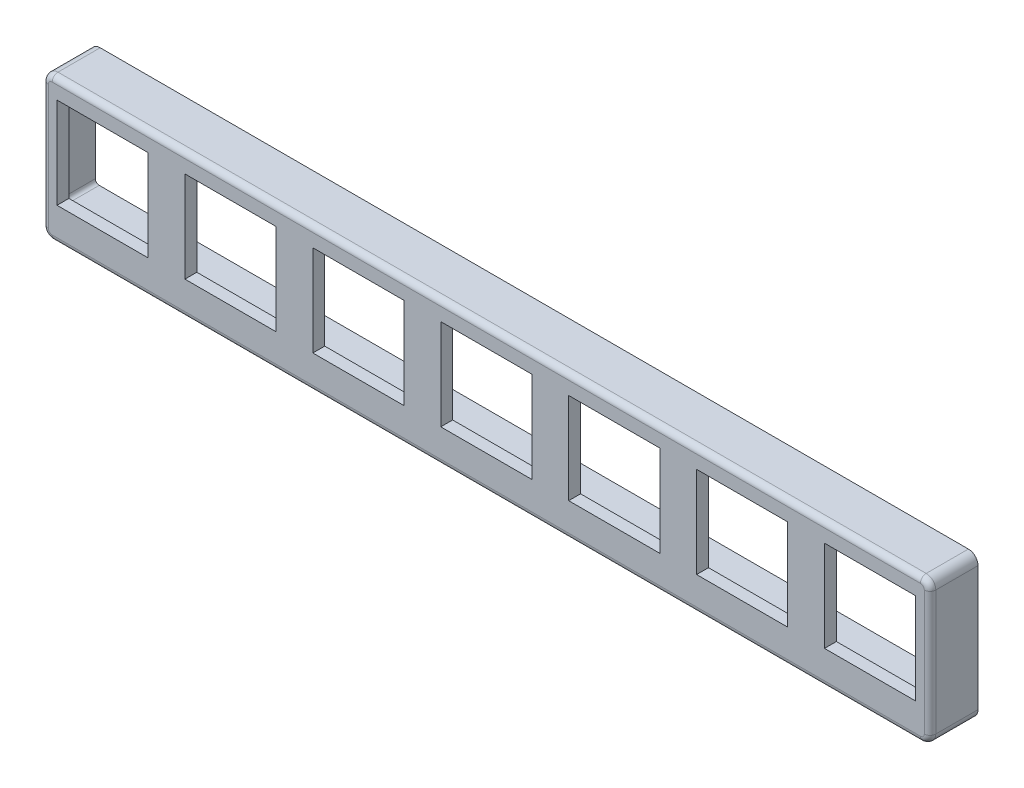
from build123d import *

# Parameters (mm, degrees)
SKETCH1_W             = 117.475
SKETCH1_H             = 19.05
BOSS_EXTRUDE1_DEPTH   = 9.525
BOSS_EXTRUDE2_DEPTH   = 3.175
F_6_CLEARANCE_HOLE1_D = 4.3053
SKETCH5_W             = 12.065
SKETCH5_H             = 12.065
CUT_EXTRUDE1_DEPTH    = 10.525
SKETCH7_W             = 116.205
SKETCH7_H             = 14.605
CUT_EXTRUDE2_DEPTH    = 7.9502
SKETCH8_W             = 117.475
SKETCH8_H             = 28.575
CUT_EXTRUDE3_DEPTH    = 3.175
FILLET2_R             = 1.27
FILLET3_R             = 0.762
FILLET4_R             = 0.508


with BuildPart() as part:
    # Sketch1 → Boss-Extrude1 (new body)
    with BuildSketch(Plane.XY):
        with Locations((0, -57.6104797)):
            Rectangle(SKETCH1_W, SKETCH1_H)
    extrude(amount=BOSS_EXTRUDE1_DEPTH)

    # Sketch2 → Boss-Extrude2 (add)
    with BuildSketch(Plane.XY):
        with BuildLine():
            Line((35.56, -48.0854797), (58.7375, -48.0854797))
            Line((58.7375, -48.0854797), (44.939976119, -39.26086832))
            ThreePointArc((44.939976119, -39.26086832), (40.410479427, -39.106525106), (38.1, -43.0054797))
            Line((38.1, -43.0054797), (38.1, -45.5454797))
            ThreePointArc((38.1, -45.5454797), (37.356051224, -47.341530924), (35.56, -48.0854797))
        make_face()
        with BuildLine():
            Line((-38.1, -45.5454797), (-38.1, -43.0054797))
            ThreePointArc((-38.1, -43.0054797), (-40.410479427, -39.106525106), (-44.939976119, -39.26086832))
            Line((-44.939976119, -39.26086832), (-58.7375, -48.0854797))
            Line((-58.7375, -48.0854797), (-35.56, -48.0854797))
            ThreePointArc((-35.56, -48.0854797), (-37.356051224, -47.341530924), (-38.1, -45.5454797))
        make_face()
    extrude(amount=BOSS_EXTRUDE2_DEPTH)

    # #6 Clearance Hole1 (through all)
    with Locations(Plane.XY.offset(3.175)):
        with Locations((42.545, -43.0054797), (-42.545, -43.0054797)):
            Hole(F_6_CLEARANCE_HOLE1_D / 2)

    # Sketch5 → Cut-Extrude1 (cut, through all)
    with BuildSketch(Plane.XY.offset(9.525)):
        with Locations((50.8, -56.6198797)):
            Rectangle(SKETCH5_W, SKETCH5_H)
        with Locations((33.866666667, -56.6198797)):
            Rectangle(SKETCH5_W, SKETCH5_H)
        with Locations((16.933333333, -56.6198797)):
            Rectangle(SKETCH5_W, SKETCH5_H)
        with Locations((0, -56.6198797)):
            Rectangle(SKETCH5_W, SKETCH5_H)
        with Locations((-16.933333333, -56.6198797)):
            Rectangle(SKETCH5_W, SKETCH5_H)
        with Locations((-33.866666667, -56.6198797)):
            Rectangle(SKETCH5_W, SKETCH5_H)
        with Locations((-50.8, -56.6198797)):
            Rectangle(SKETCH5_W, SKETCH5_H)
    extrude(amount=-CUT_EXTRUDE1_DEPTH, mode=Mode.SUBTRACT)

    # Sketch7 → Cut-Extrude2 (cut)
    with BuildSketch(Plane(origin=(0, 0, 0), x_dir=(-1, 0, 0), z_dir=(0, 0, -1))):
        with Locations((0, -56.6198797)):
            Rectangle(SKETCH7_W, SKETCH7_H)
    extrude(amount=-CUT_EXTRUDE2_DEPTH, mode=Mode.SUBTRACT)

    # Sketch8 → Cut-Extrude3 (cut)
    with BuildSketch(Plane(origin=(0, 0, 0), x_dir=(-1, 0, 0), z_dir=(0, 0, -1))):
        with Locations((0, -52.8479797)):
            Rectangle(SKETCH8_W, SKETCH8_H)
    extrude(amount=-CUT_EXTRUDE3_DEPTH, mode=Mode.SUBTRACT)

    # Fillet2
    fillet2_edges = [part.edges().sort_by_distance(p)[0] for p in [
        (58.7375, -67.1354797, 6.35),
        (58.7375, -48.0854797, 6.35),
        (-58.7375, -48.0854797, 6.35),
        (-58.7375, -67.1354797, 6.35),
    ]]
    fillet(fillet2_edges, radius=FILLET2_R)

    # Fillet3
    fillet3_edges = [part.edges().sort_by_distance(p)[0] for p in [
        (-58.7375, -57.6104797, 9.525),
        (0, -48.0854797, 9.525),
        (0, -67.1354797, 9.525),
        (58.7375, -57.6104797, 9.525),
        (58.365525612, -66.763505312, 9.525),
        (58.365525612, -48.457454088, 9.525),
        (-58.365525612, -66.763505312, 9.525),
        (-58.365525612, -48.457454088, 9.525),
    ]]
    fillet(fillet3_edges, radius=FILLET3_R)

    # Fillet4
    fillet4_edges = [part.edges().sort_by_distance(p)[0] for p in [
        (0, -63.9223797, 7.9502),
        (-58.1025, -63.9223797, 5.5626),
        (-58.1025, -56.6198797, 7.9502),
        (-58.1025, -49.3173797, 5.5626),
        (0, -49.3173797, 7.9502),
        (58.1025, -49.3173797, 5.5626),
        (58.1025, -56.6198797, 7.9502),
        (58.1025, -63.9223797, 5.5626),
    ]]
    fillet(fillet4_edges, radius=FILLET4_R)


solid = part.part
